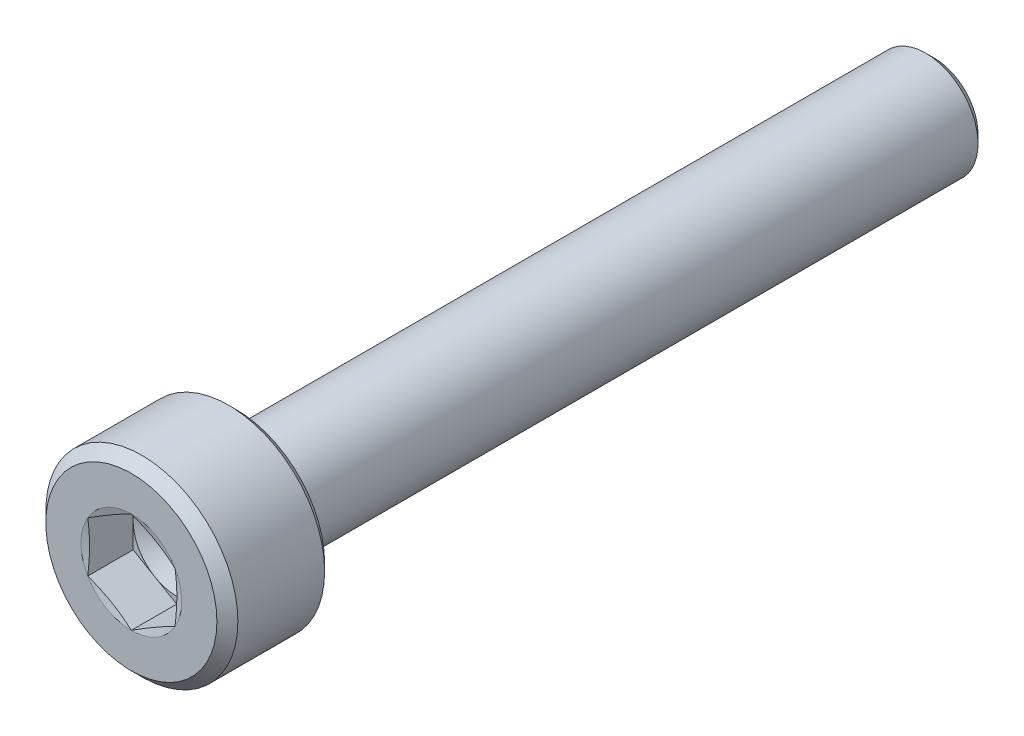
from build123d import *

# Parameters (mm, degrees)
CUT_EXTRUDE1_DEPTH = 1.3


with BuildPart() as part:
    # Sketch1 → Revolve1 (revolve)
    with BuildSketch(Plane(origin=(0, 0, 0), x_dir=(0, 0, -1), z_dir=(1, 0, 0))):
        with BuildLine():
            Line((0, 0), (0, 2.45))
            Line((0, 2.45), (0.3, 2.75))
            Line((0.3, 2.75), (2.785, 2.75))
            Line((2.785, 2.75), (3, 2.535))
            Line((3, 2.535), (3, 1.8))
            ThreePointArc((3, 1.8), (3.015193643, 1.74701055), (3.056157637, 1.710123155))
            Line((3.056157637, 1.710123155), (3.466157637, 1.510123155))
            ThreePointArc((3.466157637, 1.510123155), (3.48750205, 1.50256365), (3.51, 1.5))
            Line((3.51, 1.5), (22.75, 1.5))
            Line((22.75, 1.5), (23, 1.25))
            Line((23, 1.25), (23, 0))
            Line((23, 0), (0, 0))
        make_face()
    revolve(axis=Axis((0, 0, 0), (0, 0, -1)))

    # Sketch2 → Cut-Extrude1 (cut)
    with BuildSketch(Plane.XY):
        Polygon((0, 1.443375673), (-1.25, 0.721687836), (-1.25, -0.721687836), (0, -1.443375673), (1.25, -0.721687836), (1.25, 0.721687836), align=None)
    extrude(amount=-CUT_EXTRUDE1_DEPTH, mode=Mode.SUBTRACT)

    # Sketch3 → Cut-Revolve2 (revolve, cut)
    with BuildSketch(Plane(origin=(0, 0, 0), x_dir=(0, 0, -1), z_dir=(1, 0, 0))):
        Polygon((1.3, 0), (1.3, 1.25), (2.021687836, 0), align=None)
    revolve(axis=Axis((0, 0, -1.3), (0, 0, -1)), mode=Mode.SUBTRACT)

    # Sketch4 → Cut-Revolve3 (revolve, cut)
    with BuildSketch(Plane(origin=(0, 0, 0), x_dir=(0, 0, -1), z_dir=(1, 0, 0))):
        Polygon((0, 1.443375673), (0, 1.25), (0.051814855, 1.25), align=None)
    revolve(axis=Axis((0, 0, 0), (0, 0, -1)), mode=Mode.SUBTRACT)


solid = part.part
